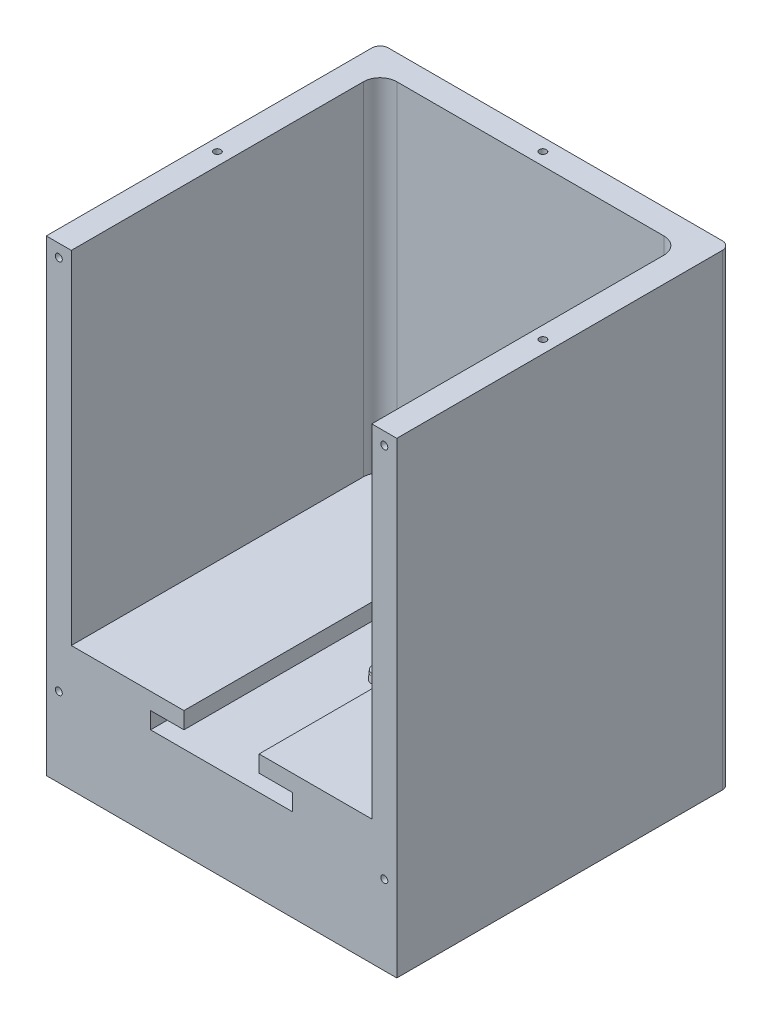
from build123d import *

# Parameters (mm, degrees)
BOSS_EXTRUDE1_DEPTH = 225
BOSS_EXTRUDE2_DEPTH = 10
SKETCH6_W           = 210
SKETCH6_H           = 200
BOSS_EXTRUDE3_DEPTH = 15
SKETCH5_R           = 2.1
CUT_EXTRUDE1_DEPTH  = 4.5
SKETCH10_W          = 210
SKETCH10_H          = 200
BOSS_EXTRUDE4_DEPTH = 40
SKETCH11_R          = 5
BOSS_EXTRUDE5_DEPTH = 5
BOSS_EXTRUDE5_TAPER = 5
SKETCH13_W          = 185
SKETCH13_H          = 10
BOSS_EXTRUDE6_DEPTH = 47.5
SKETCH14_W          = 185
SKETCH14_H          = 10
BOSS_EXTRUDE7_DEPTH = 47.5
SKETCH7_W           = 21
SKETCH7_H           = 10.25
CUT_EXTRUDE2_DEPTH  = 15
SKETCH15_R          = 2.1
CUT_EXTRUDE4_DEPTH  = 4.5
FILLET2_R           = 10
FILLET4_R           = 5


with BuildPart() as part:
    # Sketch2 → Boss-Extrude1 (new body)
    with BuildSketch(Plane(origin=(0, 0, 0), x_dir=(1, 0, 0), z_dir=(0, 1, 0))):
        Polygon((-90, 0), (90, 0), (90, -185), (105, -185), (105, 15), (-105, 15), (-105, -185), (-90, -185), align=None)
    extrude(amount=BOSS_EXTRUDE1_DEPTH)

    # Sketch3 → Boss-Extrude2 (add)
    with BuildSketch(Plane(origin=(0, 10, 0), x_dir=(1, 0, 0), z_dir=(0, 1, 0))):
        Polygon((-90, -185), (-22.5, -185), (-22.5, -10), (22.5, -10), (22.5, -185), (90, -185), (90, 0), (-90, 0), align=None)
    extrude(amount=BOSS_EXTRUDE2_DEPTH)

    # Sketch6 → Boss-Extrude3 (add)
    with BuildSketch(Plane.XZ):
        with Locations((0, 85)):
            Rectangle(SKETCH6_W, SKETCH6_H)
    extrude(amount=BOSS_EXTRUDE3_DEPTH)

    # Sketch5 → Cut-Extrude1 (cut)
    with BuildSketch(Plane.XY.offset(185)):
        with Locations((-97.5, 217.5)):
            Circle(SKETCH5_R)
        with Locations((97.5, 217.5)):
            Circle(SKETCH5_R)
        with Locations((-97.5, -7.5)):
            Circle(SKETCH5_R)
        with Locations((97.5, -7.5)):
            Circle(SKETCH5_R)
    extrude(amount=-CUT_EXTRUDE1_DEPTH, mode=Mode.SUBTRACT)

    # Sketch10 → Boss-Extrude4 (add)
    with BuildSketch(Plane.XZ.offset(15)):
        with Locations((0, 85)):
            Rectangle(SKETCH10_W, SKETCH10_H)
    extrude(amount=BOSS_EXTRUDE4_DEPTH)

    # Sketch11 → Boss-Extrude5 (add)
    with BuildSketch(Plane(origin=(0, 0, 0), x_dir=(1, 0, 0), z_dir=(0, 1, 0))):
        with Locations((0, -90)):
            Circle(SKETCH11_R)
    extrude(amount=BOSS_EXTRUDE5_DEPTH, taper=BOSS_EXTRUDE5_TAPER)

    # Sketch13 → Boss-Extrude6 (add)
    with BuildSketch(Plane.ZY.offset(-90)):
        with Locations((92.5, 5)):
            Rectangle(SKETCH13_W, SKETCH13_H)
    extrude(amount=BOSS_EXTRUDE6_DEPTH)

    # Sketch14 → Boss-Extrude7 (add)
    with BuildSketch(Plane(origin=(-90, 0, 0), x_dir=(0, 0, -1), z_dir=(1, 0, 0))):
        with Locations((-92.5, 5)):
            Rectangle(SKETCH14_W, SKETCH14_H)
    extrude(amount=BOSS_EXTRUDE7_DEPTH)

    # Sketch7 → Cut-Extrude2 (cut)
    with BuildSketch(Plane(origin=(0, 0, -15), x_dir=(-1, 0, 0), z_dir=(0, 0, -1))):
        with Locations((-32, 5.125)):
            Rectangle(SKETCH7_W, SKETCH7_H)
    extrude(amount=-CUT_EXTRUDE2_DEPTH, mode=Mode.SUBTRACT)

    # Sketch15 → Cut-Extrude4 (cut)
    with BuildSketch(Plane(origin=(0, 225, 0), x_dir=(1, 0, 0), z_dir=(0, 1, 0))):
        with Locations((0, 7.5)):
            Circle(SKETCH15_R)
        with Locations((-97.5, -90)):
            Circle(SKETCH15_R)
        with Locations((97.5, -90)):
            Circle(SKETCH15_R)
    extrude(amount=-CUT_EXTRUDE4_DEPTH, mode=Mode.SUBTRACT)

    # Fillet2
    fillet2_edges = [part.edges().sort_by_distance(p)[0] for p in [
        (90, 122.5, 0),
        (-90, 122.5, 0),
    ]]
    fillet(fillet2_edges, radius=FILLET2_R)

    # Fillet4
    fillet4_edges = [part.edges().sort_by_distance(p)[0] for p in [
        (-105, 85, -15),
        (105, 85, -15),
    ]]
    fillet(fillet4_edges, radius=FILLET4_R)


solid = part.part
